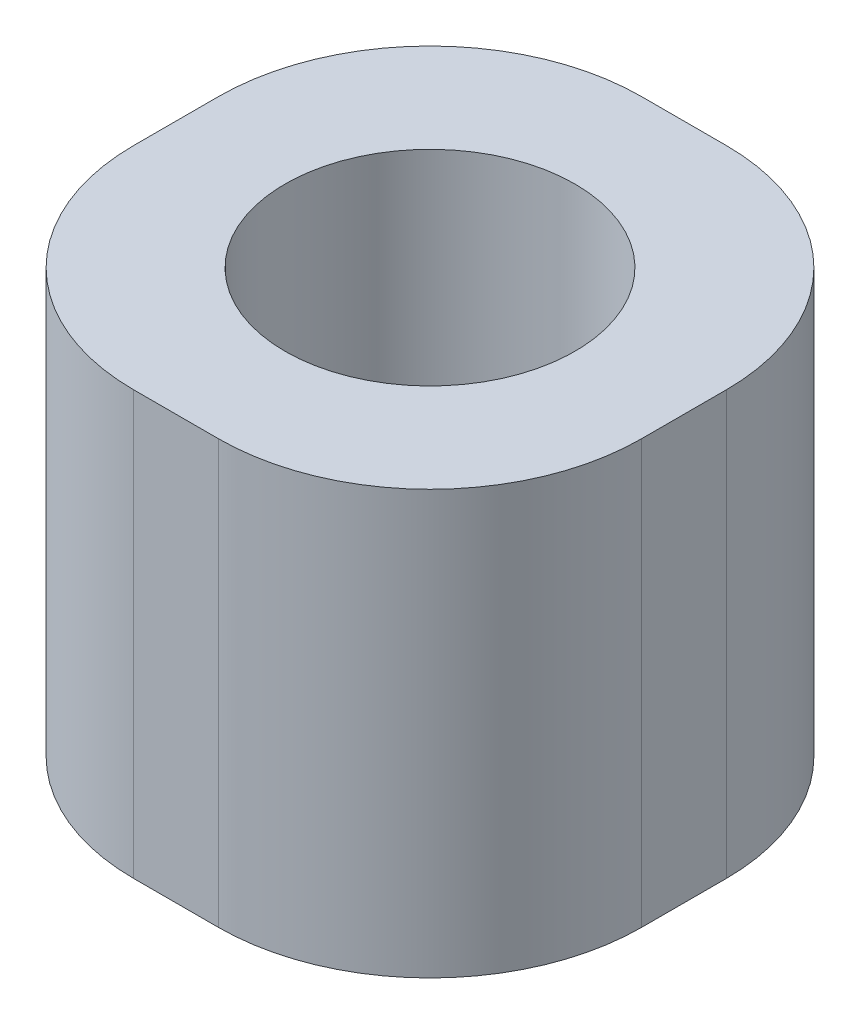
from build123d import *

# Parameters (mm, degrees)
SKETCH1_W           = 12
SKETCH1_H           = 12
BOSS_EXTRUDE1_DEPTH = 10
FILLET1_R           = 5
SKETCH2_R           = 2
CUT_EXTRUDE1_DEPTH  = 11
SKETCH3_R           = 3.425
CUT_EXTRUDE2_DEPTH  = 6.35


with BuildPart() as part:
    # Sketch1 → Boss-Extrude1 (new body)
    with BuildSketch(Plane(origin=(0, 0, 0), x_dir=(1, 0, 0), z_dir=(0, 1, 0))):
        Rectangle(SKETCH1_W, SKETCH1_H)
    extrude(amount=BOSS_EXTRUDE1_DEPTH)

    # Fillet1
    fillet1_edges = [part.edges().sort_by_distance(p)[0] for p in [
        (-6, 5, -6),
        (6, 5, -6),
        (6, 5, 6),
        (-6, 5, 6),
    ]]
    fillet(fillet1_edges, radius=FILLET1_R)

    # Sketch2 → Cut-Extrude1 (cut, through all)
    with BuildSketch(Plane(origin=(0, 10, 0), x_dir=(1, 0, 0), z_dir=(0, 1, 0))):
        Circle(SKETCH2_R)
    extrude(amount=-CUT_EXTRUDE1_DEPTH, mode=Mode.SUBTRACT)

    # Sketch3 → Cut-Extrude2 (cut)
    with BuildSketch(Plane(origin=(0, 10, 0), x_dir=(1, 0, 0), z_dir=(0, 1, 0))):
        Circle(SKETCH3_R)
    extrude(amount=-CUT_EXTRUDE2_DEPTH, mode=Mode.SUBTRACT)


solid = part.part
